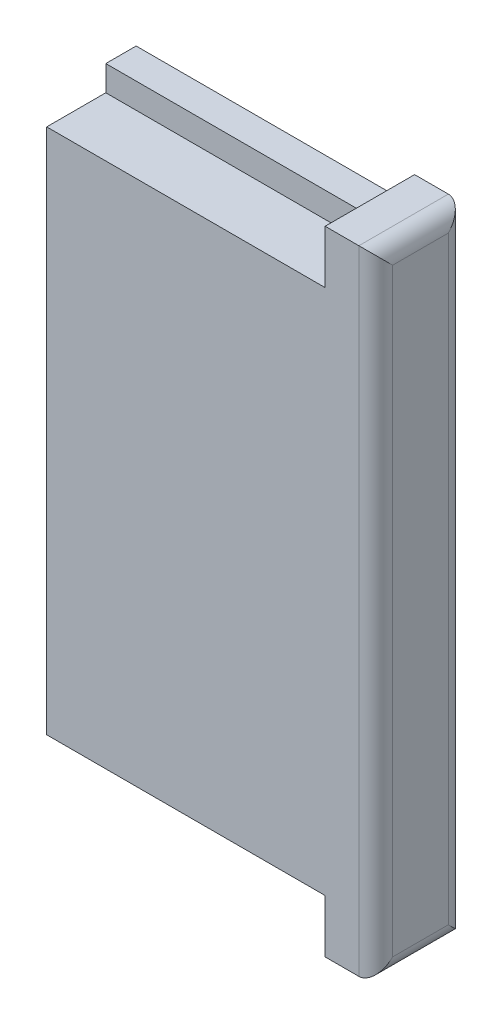
from build123d import *

# Parameters (mm, degrees)
SKETCH1_W   = 16.5
SKETCH1_H   = 34.2
INT_2_DEPTH = 1.8
SKETCH2_W   = 16.5
SKETCH2_H   = 31.2
EXT_DEPTH   = 3.5
SKETCH3_W   = 5.3
SKETCH3_H   = 37.5
TOP_DEPTH   = 3
FILLET1_R   = 1


with BuildPart() as part:
    # Sketch1 → Int 2 (new body)
    with BuildSketch(Plane.XY):
        Rectangle(SKETCH1_W, SKETCH1_H)
    extrude(amount=INT_2_DEPTH)

    # Sketch2 → Ext (add)
    with BuildSketch(Plane.XY.offset(1.8)):
        Rectangle(SKETCH2_W, SKETCH2_H)
    extrude(amount=EXT_DEPTH)

    # Sketch3 → Top (add)
    with BuildSketch(Plane(origin=(8.25, 0, 0), x_dir=(0, 0, -1), z_dir=(1, 0, 0))):
        with Locations((-2.65, 0)):
            Rectangle(SKETCH3_W, SKETCH3_H)
    extrude(amount=TOP_DEPTH)

    # Fillet1
    fillet1_edges = [part.edges().sort_by_distance(p)[0] for p in [
        (11.25, 0, 0),
        (11.25, 18.75, 2.65),
        (11.25, 0, 5.3),
        (11.25, -18.75, 2.65),
    ]]
    fillet(fillet1_edges, radius=FILLET1_R)


solid = part.part
